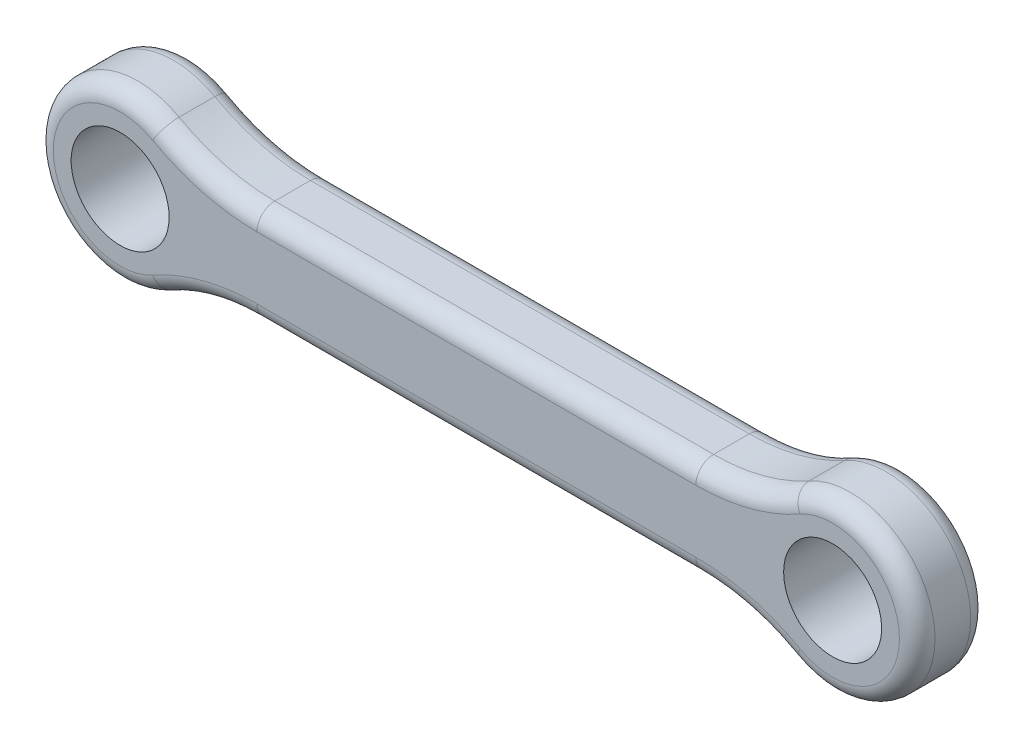
from build123d import *

# Parameters (mm, degrees)
SKETCH1_R           = 2.75
BOSS_EXTRUDE1_DEPTH = 4
FILLET1_R           = 1


with BuildPart() as part:
    # Sketch1 → Boss-Extrude1 (new body)
    with BuildSketch(Plane.XY):
        with BuildLine():
            Line((-12.318854252, -2.75), (12.318854252, -2.75))
            ThreePointArc((12.318854252, -2.75), (15.090593721, -3.104932583), (17.683463981, -4.146825397))
            ThreePointArc((17.683463981, -4.146825397), (24.75, 0), (17.683463981, 4.146825397))
            ThreePointArc((17.683463981, 4.146825397), (15.090593721, 3.104932583), (12.318854252, 2.75))
            Line((12.318854252, 2.75), (-12.318854252, 2.75))
            ThreePointArc((-12.318854252, 2.75), (-15.090593721, 3.104932583), (-17.683463981, 4.146825397))
            ThreePointArc((-17.683463981, 4.146825397), (-24.75, 0), (-17.683463981, -4.146825397))
            ThreePointArc((-17.683463981, -4.146825397), (-15.090593721, -3.104932583), (-12.318854252, -2.75))
        make_face()
        with Locations((-20, 0)):
            Circle(SKETCH1_R, mode=Mode.SUBTRACT)
        with Locations((20, 0)):
            Circle(SKETCH1_R, mode=Mode.SUBTRACT)
    extrude(amount=BOSS_EXTRUDE1_DEPTH)

    # Fillet1
    fillet1_edges = [part.edges().sort_by_distance(p)[0] for p in [
        (15.090593721, 3.104932583, 0),
        (24.75, 0, 0),
        (15.090593721, -3.104932583, 0),
        (0, -2.75, 0),
        (24.75, 0, 4),
        (15.090593721, 3.104932583, 4),
        (0, 2.75, 4),
        (-15.090593721, 3.104932583, 4),
        (-24.75, 0, 4),
        (-15.090593721, -3.104932583, 4),
        (0, -2.75, 4),
        (-15.090593721, -3.104932583, 0),
        (15.090593721, -3.104932583, 4),
        (-24.75, 0, 0),
        (-15.090593721, 3.104932583, 0),
        (0, 2.75, 0),
    ]]
    fillet(fillet1_edges, radius=FILLET1_R)


solid = part.part
